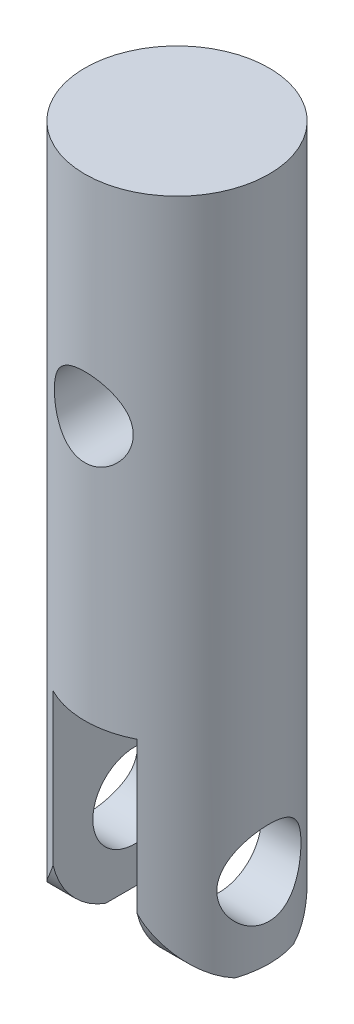
from build123d import *
from build123d.topology import SkipClean

# Parameters (mm, degrees)
SKETCH1_R               = 8.75
BOSS_EXTRUDE1_DEPTH     = 45
BOSS_EXTRUDE2_START     = 20
BOSS_EXTRUDE2_DEPTH     = 20
CUT_EXTRUDE2_DEPTH      = 15
CUT_EXTRUDE2_DEPTH_BACK = 15
SKETCH3_R               = 4
CUT_EXTRUDE3_DEPTH      = 15
CUT_EXTRUDE3_DEPTH_BACK = 15
SKETCH4_R               = 3.75


with BuildPart() as part:
    # Sketch1 → Boss-Extrude1 (new body)
    with BuildSketch(Plane(origin=(0, 0, 0), x_dir=(1, 0, 0), z_dir=(0, 1, 0))):
        Circle(SKETCH1_R)
    extrude(amount=BOSS_EXTRUDE1_DEPTH)

    # Sketch2 → Boss-Extrude2 (add)
    with SkipClean():  # the faces are left unmerged after this step: merging them gives an invalid solid
        with BuildSketch(Plane.XZ.offset(BOSS_EXTRUDE2_START)):
            with BuildLine():
                Line((-4, -7.782191208), (-4, 7.782191208))
                ThreePointArc((-4, 7.782191208), (-8.75, 0), (-4, -7.782191208))
            make_face()
            with BuildLine():
                Line((4, -7.782191208), (4, 7.782191208))
                ThreePointArc((4, 7.782191208), (8.75, 0), (4, -7.782191208))
            make_face()
        extrude(amount=-BOSS_EXTRUDE2_DEPTH)

    # Sketch3 → Cut-Extrude2 (cut, two sides: drawn at the far end of the back side and taken through both)
    with SkipClean():  # the faces are left unmerged after this step: merging them gives an invalid solid
        with BuildSketch(Plane(origin=(0, 0, 0), x_dir=(0, 0, -1), z_dir=(1, 0, 0)).offset(-CUT_EXTRUDE2_DEPTH_BACK)):
            with Locations((0, -12.5)):
                Circle(SKETCH3_R)
            with BuildLine():
                Line((-8, -12.5), (-11.944744316, -12.5))
                Line((-11.944744316, -12.5), (-11.944744316, -23.565322798))
                Line((-11.944744316, -23.565322798), (12.069953463, -23.565322798))
                Line((12.069953463, -23.565322798), (12.069953463, -12.5))
                Line((12.069953463, -12.5), (8, -12.5))
                ThreePointArc((8, -12.5), (0, -20.5), (-8, -12.5))
            make_face()
        extrude(amount=CUT_EXTRUDE2_DEPTH + CUT_EXTRUDE2_DEPTH_BACK, mode=Mode.SUBTRACT)

    # Sketch4 → Cut-Extrude3 (cut, two sides: drawn at the far end of the back side and taken through both)
    with SkipClean():  # the faces are left unmerged after this step: merging them gives an invalid solid
        with BuildSketch(Plane.XY.offset(-CUT_EXTRUDE3_DEPTH_BACK)):
            with Locations((0, 25)):
                Circle(SKETCH4_R)
        extrude(amount=CUT_EXTRUDE3_DEPTH + CUT_EXTRUDE3_DEPTH_BACK, mode=Mode.SUBTRACT)


solid = part.part
